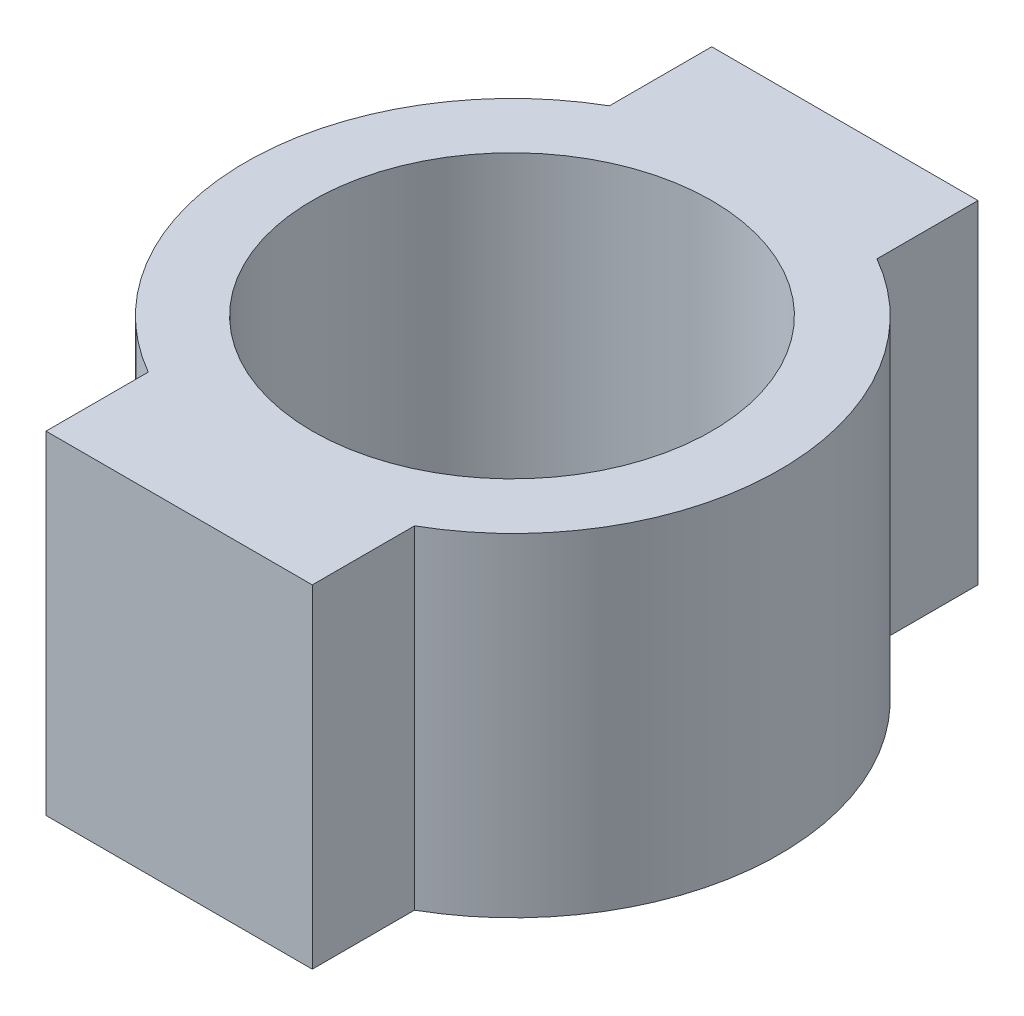
from build123d import *

# Parameters (mm, degrees)
BOSS_EXTRUDE1_DEPTH = 50
SKETCH2_R           = 30
CUT_EXTRUDE1_DEPTH  = 50


with BuildPart() as part:
    # Sketch1 → Boss-Extrude1 (new body)
    with BuildSketch(Plane(origin=(0, 0, 0), x_dir=(1, 0, 0), z_dir=(0, 1, 0))):
        with BuildLine():
            Line((-20, 50), (20, 50))
            Line((20, 50), (20, 34.818623064))
            ThreePointArc((20, 34.818623064), (40.154606831, 0.088803456), (20, -34.641016151))
            Line((20, -34.641016151), (20, -50))
            Line((20, -50), (-20, -50))
            Line((-20, -50), (-20, -34.641016151))
            ThreePointArc((-20, -34.641016151), (-40, 0), (-20, 34.641016151))
            Line((-20, 34.641016151), (-20, 50))
        make_face()
    extrude(amount=BOSS_EXTRUDE1_DEPTH)

    # Sketch2 → Cut-Extrude1 (cut)
    with BuildSketch(Plane(origin=(0, 50, 0), x_dir=(1, 0, 0), z_dir=(0, 1, 0))):
        Circle(SKETCH2_R)
    extrude(amount=-CUT_EXTRUDE1_DEPTH, mode=Mode.SUBTRACT)


solid = part.part
